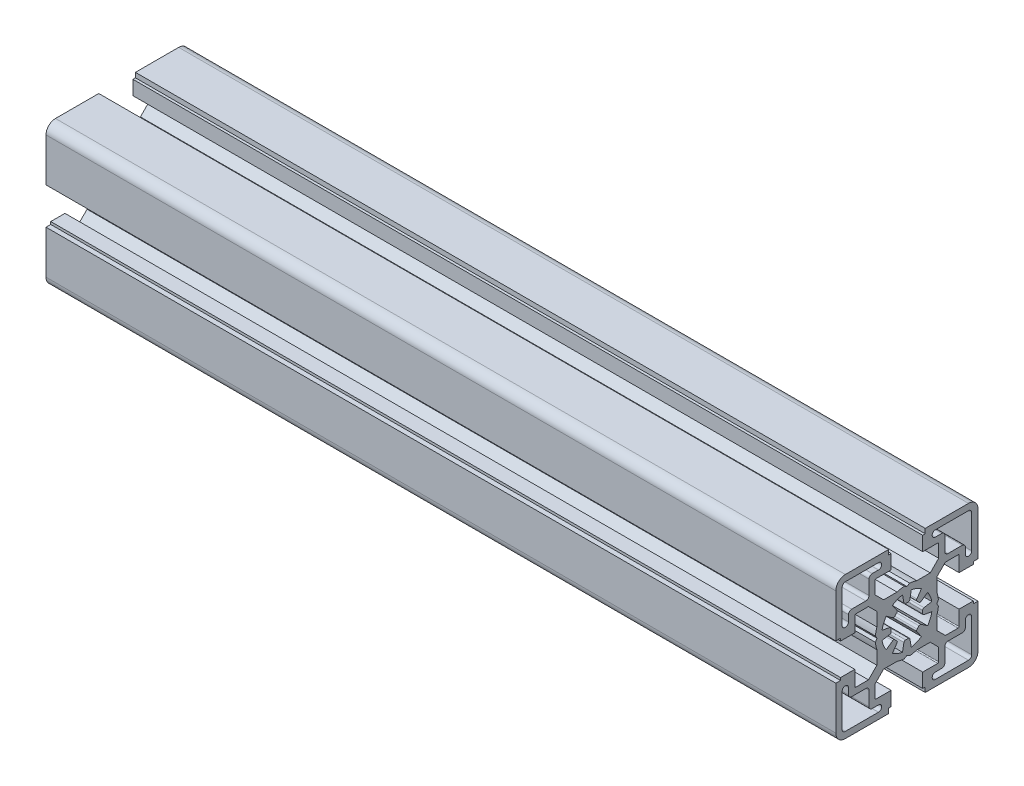
from build123d import *

# Parameters (mm, degrees)
EXTRUDE_1_DEPTH     = 250
CUT_EXTRUDE_1_DEPTH = 251


with BuildPart() as part:
    # Эскиз2 → Бобышка-Вытянуть1 (new body)
    with BuildSketch(Plane(origin=(0, 0, 0), x_dir=(0, 0, -1), z_dir=(1, 0, 0))):
        with BuildLine():
            Line((16.5, 5), (21, 5))
            Line((21, 5), (21, 5.799999))
            Line((21, 5.799999), (22.5, 5.799999))
            Line((22.5, 5.799999), (22.5, 19.5))
            ThreePointArc((22.5, 19.5), (21.621320344, 21.621320344), (19.5, 22.5))
            Line((19.5, 22.5), (5.799999, 22.5))
            Line((5.799999, 22.5), (5.799999, 21))
            Line((5.799999, 21), (5, 21))
            Line((5, 21), (5, 16.5))
            Line((5, 16.5), (9.75, 16.5))
            ThreePointArc((9.75, 16.5), (9.962132034, 16.412132034), (10.05, 16.2))
            Line((10.05, 16.2), (10.05, 12.171320344))
            Line((10.05, 12.171320344), (7.378679656, 9.5))
            Line((7.378679656, 9.5), (3.122498999, 9.5))
            ThreePointArc((3.122498999, 9.5), (2.007620973, 9.796400259), (0.866025404, 9.962429423))
            Line((0.866025404, 9.962429423), (0, 9.462429423))
            Line((0, 9.462429423), (-0.866025404, 9.962429423))
            ThreePointArc((-0.866025404, 9.962429423), (-2.007620973, 9.796400259), (-3.122498999, 9.5))
            Line((-3.122498999, 9.5), (-7.378679656, 9.5))
            Line((-7.378679656, 9.5), (-10.049999, 12.171319344))
            Line((-10.049999, 12.171319344), (-10.049999, 16.2))
            ThreePointArc((-10.049999, 16.2), (-9.962131034, 16.412132034), (-9.749999, 16.5))
            Line((-9.749999, 16.5), (-5, 16.5))
            Line((-5, 16.5), (-5, 21))
            Line((-5, 21), (-5.799999, 21))
            Line((-5.799999, 21), (-5.799999, 22.5))
            Line((-5.799999, 22.5), (-19.5, 22.5))
            ThreePointArc((-19.5, 22.5), (-21.621320344, 21.621320344), (-22.5, 19.5))
            Line((-22.5, 19.5), (-22.5, 5.799999))
            Line((-22.5, 5.799999), (-21, 5.799999))
            Line((-21, 5.799999), (-21, 5))
            Line((-21, 5), (-16.5, 5))
            Line((-16.5, 5), (-16.5, 9.749999))
            ThreePointArc((-16.5, 9.749999), (-16.412132034, 9.962131034), (-16.2, 10.049999))
            Line((-16.2, 10.049999), (-12.171319344, 10.049999))
            Line((-12.171319344, 10.049999), (-9.5, 7.378679656))
            Line((-9.5, 7.378679656), (-9.5, 3.122498999))
            ThreePointArc((-9.5, 3.122498999), (-9.796400259, 2.007620973), (-9.962429423, 0.866025404))
            Line((-9.962429423, 0.866025404), (-9.462429423, 0))
            Line((-9.462429423, 0), (-9.962429423, -0.866025404))
            ThreePointArc((-9.962429423, -0.866025404), (-9.796400259, -2.007620973), (-9.5, -3.122498999))
            Line((-9.5, -3.122498999), (-9.5, -7.378679656))
            Line((-9.5, -7.378679656), (-12.171320344, -10.05))
            Line((-12.171320344, -10.05), (-16.2, -10.05))
            ThreePointArc((-16.2, -10.05), (-16.412132034, -9.962132034), (-16.5, -9.75))
            Line((-16.5, -9.75), (-16.5, -5))
            Line((-16.5, -5), (-21, -5))
            Line((-21, -5), (-21, -5.799999))
            Line((-21, -5.799999), (-22.5, -5.799999))
            Line((-22.5, -5.799999), (-22.5, -19.5))
            ThreePointArc((-22.5, -19.5), (-21.621320344, -21.621320344), (-19.5, -22.5))
            Line((-19.5, -22.5), (-5.799999, -22.5))
            Line((-5.799999, -22.5), (-5.799999, -21))
            Line((-5.799999, -21), (-5, -21))
            Line((-5, -21), (-5, -16.5))
            Line((-5, -16.5), (-9.749999, -16.5))
            ThreePointArc((-9.749999, -16.5), (-9.962131034, -16.412132034), (-10.049999, -16.2))
            Line((-10.049999, -16.2), (-10.049999, -12.171319344))
            Line((-10.049999, -12.171319344), (-7.378679656, -9.5))
            Line((-7.378679656, -9.5), (-3.122498999, -9.5))
            ThreePointArc((-3.122498999, -9.5), (-2.007620973, -9.796400259), (-0.866025404, -9.962429423))
            Line((-0.866025404, -9.962429423), (0, -9.462429423))
            Line((0, -9.462429423), (0.866025404, -9.962429423))
            ThreePointArc((0.866025404, -9.962429423), (2.007620973, -9.796400259), (3.122498999, -9.5))
            Line((3.122498999, -9.5), (7.378679656, -9.5))
            Line((7.378679656, -9.5), (10.05, -12.171320344))
            Line((10.05, -12.171320344), (10.05, -16.2))
            ThreePointArc((10.05, -16.2), (9.962132034, -16.412132034), (9.75, -16.5))
            Line((9.75, -16.5), (5, -16.5))
            Line((5, -16.5), (5, -21))
            Line((5, -21), (5.799999, -21))
            Line((5.799999, -21), (5.799999, -22.5))
            Line((5.799999, -22.5), (19.5, -22.5))
            ThreePointArc((19.5, -22.5), (21.621320344, -21.621320344), (22.5, -19.5))
            Line((22.5, -19.5), (22.5, -5.799999))
            Line((22.5, -5.799999), (21, -5.799999))
            Line((21, -5.799999), (21, -5))
            Line((21, -5), (16.5, -5))
            Line((16.5, -5), (16.5, -9.75))
            ThreePointArc((16.5, -9.75), (16.412132034, -9.962132034), (16.2, -10.05))
            Line((16.2, -10.05), (12.171320344, -10.05))
            Line((12.171320344, -10.05), (9.5, -7.378679656))
            Line((9.5, -7.378679656), (9.5, -3.122498999))
            ThreePointArc((9.5, -3.122498999), (9.796400259, -2.007620973), (9.962429423, -0.866025404))
            Line((9.962429423, -0.866025404), (9.462429423, 0))
            Line((9.462429423, 0), (9.962429423, 0.866025404))
            ThreePointArc((9.962429423, 0.866025404), (9.796400259, 2.007620973), (9.5, 3.122498999))
            Line((9.5, 3.122498999), (9.5, 7.378679656))
            Line((9.5, 7.378679656), (12.171319344, 10.049999))
            Line((12.171319344, 10.049999), (16.2, 10.049999))
            ThreePointArc((16.2, 10.049999), (16.412132034, 9.962131034), (16.5, 9.749999))
            Line((16.5, 9.749999), (16.5, 5))
        make_face()
    extrude(amount=EXTRUDE_1_DEPTH)

    # Эскиз3 → Вырез-Вытянуть1 (cut, through all)
    with BuildSketch(Plane.ZY):
        with BuildLine():
            Line((-0.951109584, 5.394014463), (-1.38918508, 7.878462452))
            ThreePointArc((-1.38918508, 7.878462452), (-3.061467429, 7.391036664), (-4.588611737, 6.553216624))
            Line((-4.588611737, 6.553216624), (-3.14160736, 4.486680308))
            ThreePointArc((-3.14160736, 4.486680308), (-3.055338858, 4.135563126), (-3.228348507, 3.81808369))
            ThreePointArc((-3.228348507, 3.81808369), (-3.535533704, 3.535533704), (-3.81808369, 3.228348507))
            ThreePointArc((-3.81808369, 3.228348507), (-4.135563126, 3.055338858), (-4.486680308, 3.14160736))
            Line((-4.486680308, 3.14160736), (-6.553216624, 4.588611737))
            ThreePointArc((-6.553216624, 4.588611737), (-7.391036664, 3.061467429), (-7.878462452, 1.38918508))
            Line((-7.878462452, 1.38918508), (-5.394014463, 0.951109584))
            ThreePointArc((-5.394014463, 0.951109584), (-5.084736142, 0.763833295), (-4.982580573, 0.417005199))
            ThreePointArc((-4.982580573, 0.417005199), (-5.000000251, 0), (-4.982580573, -0.417005199))
            ThreePointArc((-4.982580573, -0.417005199), (-5.084736142, -0.763833295), (-5.394014463, -0.951109584))
            Line((-5.394014463, -0.951109584), (-7.878461766, -1.389184959))
            ThreePointArc((-7.878461766, -1.389184959), (-7.391036076, -3.06146703), (-6.553216219, -4.588611102))
            Line((-6.553216219, -4.588611102), (-4.486680308, -3.14160736))
            ThreePointArc((-4.486680308, -3.14160736), (-4.135563126, -3.055338858), (-3.81808369, -3.228348507))
            ThreePointArc((-3.81808369, -3.228348507), (-3.535533733, -3.535533675), (-3.22834857, -3.818083636))
            ThreePointArc((-3.22834857, -3.818083636), (-3.055338921, -4.135563118), (-3.141607485, -4.486680327))
            Line((-3.141607485, -4.486680327), (-4.588611972, -6.55321596))
            ThreePointArc((-4.588611972, -6.55321596), (-3.061467529, -7.39103618), (-1.38918499, -7.878462052))
            Line((-1.38918499, -7.878462052), (-0.951109584, -5.394014463))
            ThreePointArc((-0.951109584, -5.394014463), (-0.763833295, -5.084736142), (-0.417005199, -4.982580573))
            ThreePointArc((-0.417005199, -4.982580573), (0, -5.000000251), (0.417005199, -4.982580573))
            ThreePointArc((0.417005199, -4.982580573), (0.763833295, -5.084736142), (0.951109584, -5.394014463))
            Line((0.951109584, -5.394014463), (1.389184959, -7.878461766))
            ThreePointArc((1.389184959, -7.878461766), (3.061467283, -7.391035971), (4.58861155, -6.553215905))
            Line((4.58861155, -6.553215905), (3.141607485, -4.486680327))
            ThreePointArc((3.141607485, -4.486680327), (3.055338921, -4.135563118), (3.22834857, -3.818083636))
            ThreePointArc((3.22834857, -3.818083636), (3.535533704, -3.535533704), (3.818083636, -3.22834857))
            ThreePointArc((3.818083636, -3.22834857), (4.135563118, -3.055338921), (4.486680327, -3.141607485))
            Line((4.486680327, -3.141607485), (6.55321596, -4.588611972))
            ThreePointArc((6.55321596, -4.588611972), (7.39103618, -3.061467529), (7.878462052, -1.38918499))
            Line((7.878462052, -1.38918499), (5.394014463, -0.951109584))
            ThreePointArc((5.394014463, -0.951109584), (5.084736142, -0.763833295), (4.982580573, -0.417005199))
            ThreePointArc((4.982580573, -0.417005199), (5.000000251, 0), (4.982580573, 0.417005199))
            ThreePointArc((4.982580573, 0.417005199), (5.084736142, 0.763833295), (5.394014463, 0.951109584))
            Line((5.394014463, 0.951109584), (7.878462049, 1.389185009))
            ThreePointArc((7.878462049, 1.389185009), (7.391036176, 3.061467538), (6.55321596, 4.588611972))
            Line((6.55321596, 4.588611972), (4.486680327, 3.141607485))
            ThreePointArc((4.486680327, 3.141607485), (4.135563118, 3.055338921), (3.818083636, 3.22834857))
            ThreePointArc((3.818083636, 3.22834857), (3.535533675, 3.535533733), (3.228348507, 3.81808369))
            ThreePointArc((3.228348507, 3.81808369), (3.055338858, 4.135563126), (3.14160736, 4.486680308))
            Line((3.14160736, 4.486680308), (4.588611737, 6.553216624))
            ThreePointArc((4.588611737, 6.553216624), (3.061467429, 7.391036664), (1.38918508, 7.878462452))
            Line((1.38918508, 7.878462452), (0.951109584, 5.394014463))
            ThreePointArc((0.951109584, 5.394014463), (0.763833295, 5.084736142), (0.417005199, 4.982580573))
            ThreePointArc((0.417005199, 4.982580573), (0, 5.000000251), (-0.417005199, 4.982580573))
            ThreePointArc((-0.417005199, 4.982580573), (-0.763833295, 5.084736142), (-0.951109584, 5.394014463))
        make_face()
        with BuildLine():
            Line((-17.5, 12), (-13, 12))
            ThreePointArc((-13, 12), (-12.292894344, 12.292894094), (-12.000002, 13.000000474))
            Line((-12.000002, 13.000000474), (-12, 17.5))
            ThreePointArc((-12, 17.5), (-11.707106781, 18.207106781), (-11, 18.5))
            Line((-11, 18.5), (-9, 18.5))
            ThreePointArc((-9, 18.5), (-8, 19.5), (-9, 20.5))
            Line((-9, 20.5), (-19.5, 20.5))
            ThreePointArc((-19.5, 20.5), (-20.207106781, 20.207106781), (-20.5, 19.5))
            Line((-20.5, 19.5), (-20.5, 9))
            ThreePointArc((-20.5, 9), (-19.5, 8), (-18.5, 9))
            Line((-18.5, 9), (-18.5, 11))
            ThreePointArc((-18.5, 11), (-18.207106781, 11.707106781), (-17.5, 12))
        make_face()
        with BuildLine():
            Line((17.5, 12), (13.000000474, 12.000002))
            ThreePointArc((13.000000474, 12.000002), (12.292894094, 12.292894344), (12, 13))
            Line((12, 13), (12, 17.5))
            ThreePointArc((12, 17.5), (11.707106781, 18.207106781), (11, 18.5))
            Line((11, 18.5), (9, 18.5))
            ThreePointArc((9, 18.5), (8, 19.5), (9, 20.5))
            Line((9, 20.5), (19.5, 20.5))
            ThreePointArc((19.5, 20.5), (20.207106781, 20.207106781), (20.5, 19.5))
            Line((20.5, 19.5), (20.5, 9))
            ThreePointArc((20.5, 9), (19.5, 8), (18.5, 9))
            Line((18.5, 9), (18.5, 11))
            ThreePointArc((18.5, 11), (18.207106781, 11.707106781), (17.5, 12))
        make_face()
        with BuildLine():
            Line((-17.5, -12), (-13.000000474, -12.000002))
            ThreePointArc((-13.000000474, -12.000002), (-12.292894094, -12.292894344), (-12, -13))
            Line((-12, -13), (-12, -17.5))
            ThreePointArc((-12, -17.5), (-11.707106781, -18.207106781), (-11, -18.5))
            Line((-11, -18.5), (-9, -18.5))
            ThreePointArc((-9, -18.5), (-8, -19.5), (-9, -20.5))
            Line((-9, -20.5), (-19.5, -20.5))
            ThreePointArc((-19.5, -20.5), (-20.207106781, -20.207106781), (-20.5, -19.5))
            Line((-20.5, -19.5), (-20.5, -9))
            ThreePointArc((-20.5, -9), (-19.5, -8), (-18.5, -9))
            Line((-18.5, -9), (-18.5, -11))
            ThreePointArc((-18.5, -11), (-18.207106781, -11.707106781), (-17.5, -12))
        make_face()
        with BuildLine():
            Line((19.5, -20.5), (9, -20.5))
            ThreePointArc((9, -20.5), (8, -19.5), (9, -18.5))
            Line((9, -18.5), (11, -18.5))
            ThreePointArc((11, -18.5), (11.707106781, -18.207106781), (12, -17.5))
            Line((12, -17.5), (12.000002, -13.000000474))
            ThreePointArc((12.000002, -13.000000474), (12.292894344, -12.292894094), (13, -12))
            Line((13, -12), (17.5, -12))
            ThreePointArc((17.5, -12), (18.207106781, -11.707106781), (18.5, -11))
            Line((18.5, -11), (18.5, -9))
            ThreePointArc((18.5, -9), (19.5, -8), (20.5, -9))
            Line((20.5, -9), (20.5, -19.5))
            ThreePointArc((20.5, -19.5), (20.207106781, -20.207106781), (19.5, -20.5))
        make_face()
    extrude(amount=-CUT_EXTRUDE_1_DEPTH, mode=Mode.SUBTRACT)


solid = part.part
